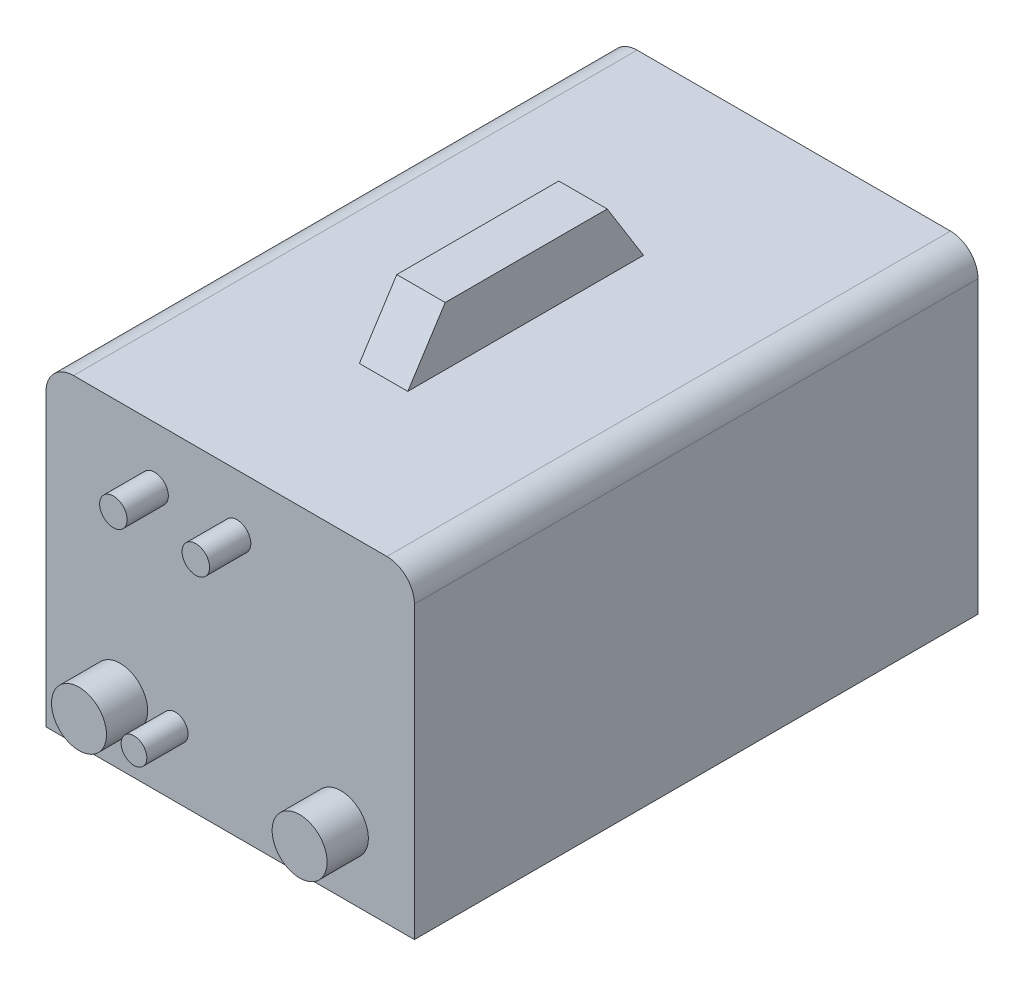
from build123d import *

# Parameters (mm, degrees)
EXTRUDE_1_DEPTH     = 410
CUT_EXTRUDE_1_DEPTH = 165
SKETCH_4_R          = 20
SKETCH_4_R_2        = 9.341042427
SKETCH_4_R_3        = 10
EXTRUDE_2_DEPTH     = 30
SKETCH_5_R          = 8.254931616
SKETCH_5_R_2        = 9.226679221
EXTRUDE_3_DEPTH     = 30


with BuildPart() as part:
    # Эскиз2 → Бобышка-Вытянуть1 (new body)
    with BuildSketch(Plane.XY):
        with BuildLine():
            Line((-134, 0), (134, 0))
            Line((134, 0), (134, 211.383370155))
            ThreePointArc((134, 211.383370155), (128.142135624, 225.525505779), (114, 231.383370155))
            Line((114, 231.383370155), (17.613812431, 231.383370155))
            Line((17.613812431, 231.383370155), (17.613812431, 273.795473599))
            Line((17.613812431, 273.795473599), (-17.613812431, 273.795473599))
            Line((-17.613812431, 273.795473599), (-17.613812431, 231.383370155))
            Line((-17.613812431, 231.383370155), (-114, 231.383370155))
            ThreePointArc((-114, 231.383370155), (-128.142135624, 225.525505779), (-134, 211.383370155))
            Line((-134, 211.383370155), (-134, 0))
        make_face()
    extrude(amount=EXTRUDE_1_DEPTH)

    # Эскиз3 → Вырез-Вытянуть1 (cut, symmetric)
    with BuildSketch(Plane(origin=(0, 0, 0), x_dir=(0, 0, -1), z_dir=(1, 0, 0))):
        Polygon((-271.206372328, 273.795473599), (-298.41124171, 231.383370155), (-410.493924083, 231.383370155), (-410.493924083, 334.856445818), (0, 334.856445818), (0, 231.383370155), (-126.94500188, 231.383370155), (-153.338385259, 273.795473599), align=None)
    extrude(amount=CUT_EXTRUDE_1_DEPTH, both=True, mode=Mode.SUBTRACT)

    # Эскиз4 → Бобышка-Вытянуть2 (add)
    with BuildSketch(Plane.XY.offset(410)):
        with Locations((-80, 47.069313646)):
            Circle(SKETCH_4_R)
        with Locations((-40, 47.069313646)):
            Circle(SKETCH_4_R_2)
        with Locations((80.509329497, 47.069313646)):
            Circle(SKETCH_4_R)
        with Locations((-55, 190)):
            Circle(SKETCH_4_R_3)
        with Locations((5, 190)):
            Circle(SKETCH_4_R_3)
    extrude(amount=EXTRUDE_2_DEPTH)

    # Эскиз5 → Бобышка-Вытянуть3 (add)
    with BuildSketch(Plane(origin=(0, 0, 0), x_dir=(-1, 0, 0), z_dir=(0, 0, -1))):
        with Locations((-12.302238961, 29.934052236)):
            Circle(SKETCH_5_R)
        with Locations((-73.813433765, 29.934052236)):
            Circle(SKETCH_5_R_2)
    extrude(amount=EXTRUDE_3_DEPTH)


solid = part.part
